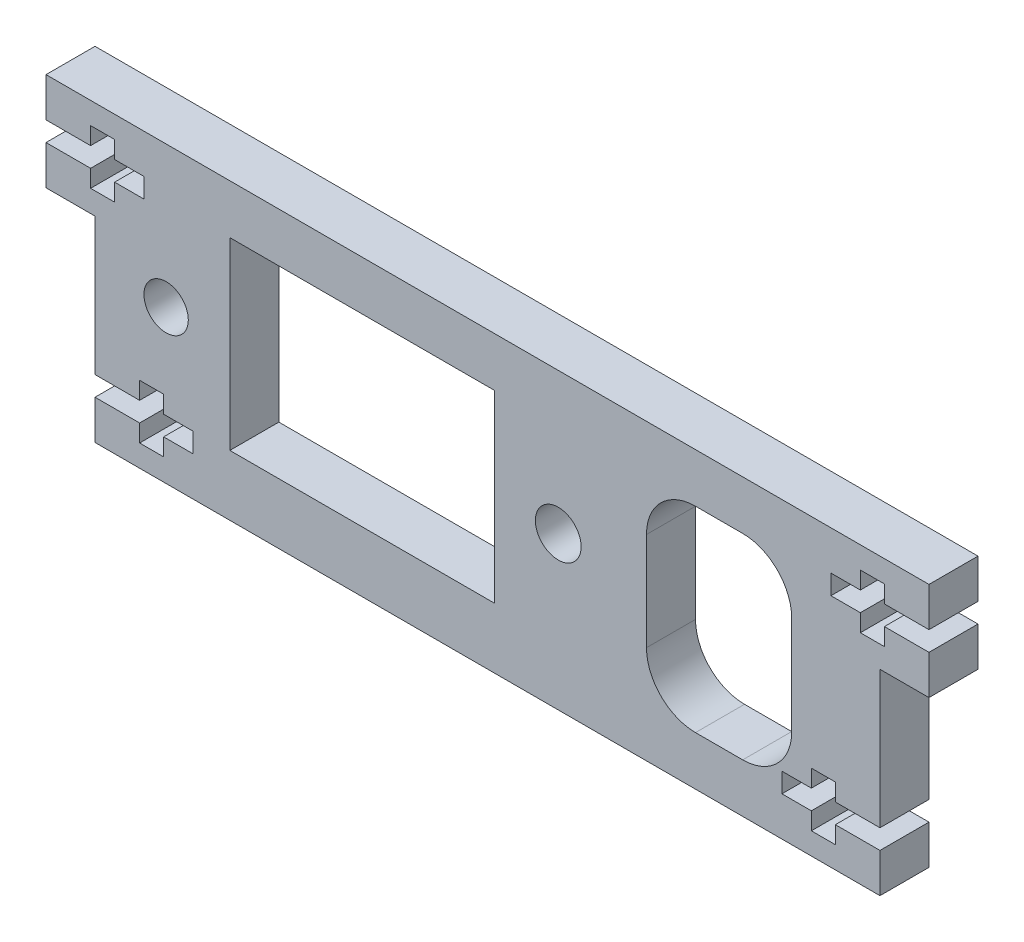
from build123d import *

# Parameters (mm, degrees)
RESSALTO_EXTRUS_O1_DEPTH = 5
CORTE_EXTRUS_O1_DEPTH    = 6
ESBO_O3_R                = 2.262708027
ESBO_O3_R_2              = 2.332727501
ESBO_O3_W                = 27
ESBO_O3_H                = 18.8
CORTE_EXTRUS_O2_DEPTH    = 6


with BuildPart() as part:
    # Esboço1 → Ressalto-extrusão1 (new body)
    with BuildSketch(Plane.XY):
        Polygon((-26.727783806, -21.587024793), (-26.727783806, -1.587024793), (-31.727783806, -1.587024793), (-31.727783806, 8.412975207), (58.342216194, 8.412975207), (58.342216194, -1.587024793), (53.342216194, -1.587024793), (53.342216194, -21.587024793), align=None)
    extrude(amount=RESSALTO_EXTRUS_O1_DEPTH)

    # Esboço2 → Corte-extrusão1 (cut, through all)
    with BuildSketch(Plane.XY.offset(5)):
        Polygon((-31.727783806, 2.412975207), (-27.177783806, 2.412975207), (-27.177783806, 0.642975207), (-24.727783806, 0.642975207), (-24.727783806, 2.412975207), (-21.727783806, 2.412975207), (-21.727783806, 4.412975207), (-24.727783806, 4.412975207), (-24.727783806, 6.182975207), (-27.177783806, 6.182975207), (-27.177783806, 4.412975207), (-31.727783806, 4.412975207), align=None)
        Polygon((51.342216194, 4.412975207), (48.342216194, 4.412975207), (48.342216194, 2.412975207), (51.342216194, 2.412975207), (51.342216194, 0.642975207), (53.792216194, 0.642975207), (53.792216194, 2.412975207), (58.342216194, 2.412975207), (58.342216194, 4.412975207), (53.792216194, 4.412975207), (53.792216194, 6.182975207), (51.342216194, 6.182975207), align=None)
        Polygon((-26.727783806, -17.587024793), (-22.177783806, -17.587024793), (-22.177783806, -19.357024793), (-19.727783806, -19.357024793), (-19.727783806, -17.587024793), (-16.727783806, -17.587024793), (-16.727783806, -15.587024793), (-19.727783806, -15.587024793), (-19.727783806, -13.817024793), (-22.177783806, -13.817024793), (-22.177783806, -15.587024793), (-26.727783806, -15.587024793), align=None)
        Polygon((46.342216194, -15.587024793), (43.342216194, -15.587024793), (43.342216194, -17.587024793), (46.342216194, -17.587024793), (46.342216194, -19.357024793), (48.792216194, -19.357024793), (48.792216194, -17.587024793), (53.342216194, -17.587024793), (53.342216194, -15.587024793), (48.792216194, -15.587024793), (48.792216194, -13.817024793), (46.342216194, -13.817024793), align=None)
    extrude(amount=-CORTE_EXTRUS_O1_DEPTH, mode=Mode.SUBTRACT)

    # Esboço3 → Corte-extrusão2 (cut, through all)
    with BuildSketch(Plane.XY.offset(5)):
        with Locations((-19.474846983, -6.010345645)):
            Circle(ESBO_O3_R)
        with Locations((20.525153017, -6.010345645)):
            Circle(ESBO_O3_R_2)
        with Locations((0.525153017, -6.010345645)):
            Rectangle(ESBO_O3_W, ESBO_O3_H)
        with BuildLine():
            Line((34.525153017, 3.412975207), (39.342216194, 3.412975207))
            ThreePointArc((39.342216194, 3.412975207), (42.8777501, 1.948509113), (44.342216194, -1.587024793))
            Line((44.342216194, -1.587024793), (44.342216194, -11.587024793))
            ThreePointArc((44.342216194, -11.587024793), (42.8777501, -15.122558699), (39.342216194, -16.587024793))
            Line((39.342216194, -16.587024793), (34.525153017, -16.587024793))
            ThreePointArc((34.525153017, -16.587024793), (30.989619111, -15.122558699), (29.525153017, -11.587024793))
            Line((29.525153017, -11.587024793), (29.525153017, -1.587024793))
            ThreePointArc((29.525153017, -1.587024793), (30.989619111, 1.948509113), (34.525153017, 3.412975207))
        make_face()
    extrude(amount=-CORTE_EXTRUS_O2_DEPTH, mode=Mode.SUBTRACT)


solid = part.part
